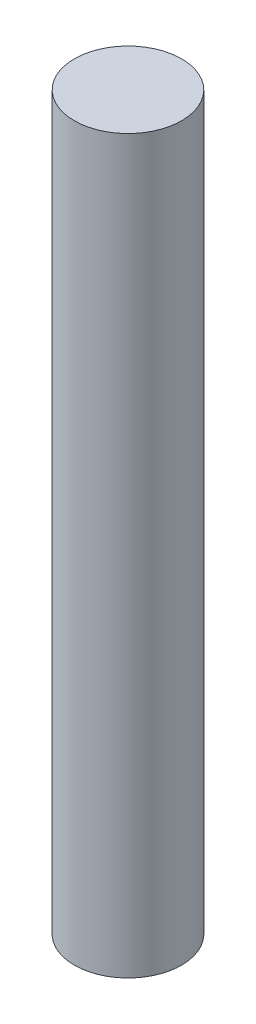
from build123d import *

# Parameters (mm, degrees)
SKETCH1_R           = 1.1
BOSS_EXTRUDE2_DEPTH = 15


with BuildPart() as part:
    # Sketch1 → Boss-Extrude2 (new body)
    with BuildSketch(Plane(origin=(0, 0, 0), x_dir=(1, 0, 0), z_dir=(0, 1, 0))):
        Circle(SKETCH1_R)
    extrude(amount=BOSS_EXTRUDE2_DEPTH)


solid = part.part
